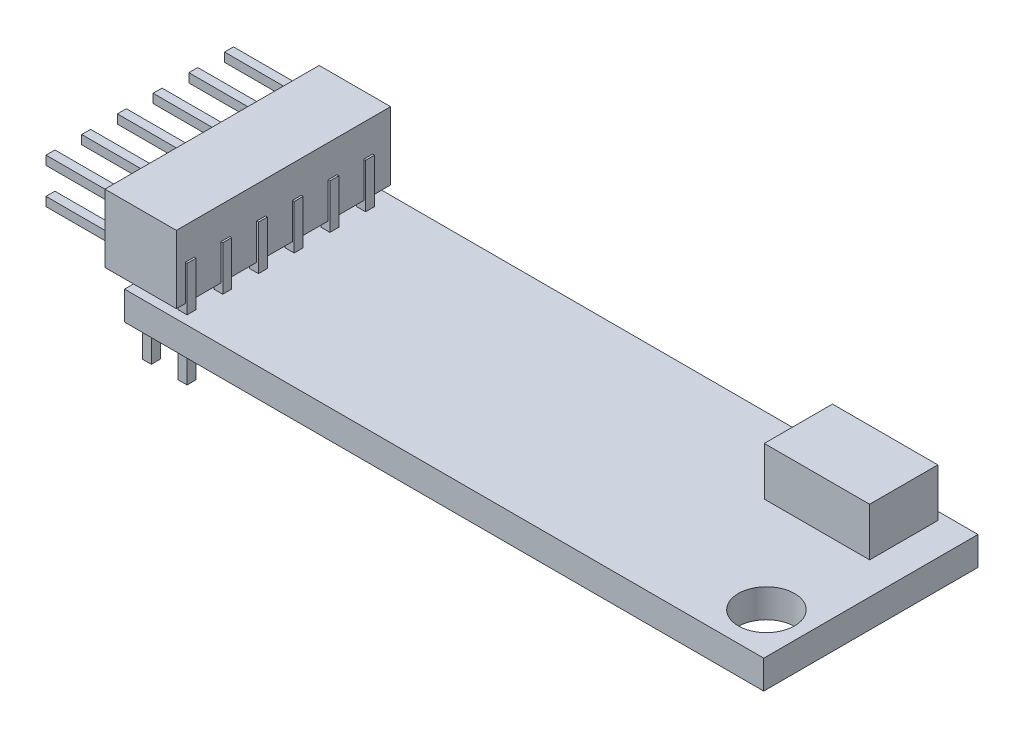
from build123d import *

# Parameters (mm, degrees)
SKETCH1_W                = 35.8
SKETCH1_H                = 12
BOARD_DEPTH              = 1.6
SKETCH2_R                = 1.575
HOLE_DEPTH               = 2.6
SKETCH3_W                = 5.9
SKETCH3_H                = 3.82
SETUP_SWITCH_DEPTH       = 2.7
SURFACE_START            = -3.4
SKETCH4_W                = 0.5
SKETCH4_H                = 0.5
SURFACE_CONNECTORS_DEPTH = 5.9
LPATTERN1_COUNT          = 6
LPATTERN1_PITCH          = 2
LPATTERN1_COUNT_DIR2     = 2
LPATTERN1_PITCH_DIR2     = 2
SKETCH5_W                = 4
SKETCH5_H                = 3.8
CONNECTOR_BODY_DEPTH     = 12
SKETCH6_W                = 0.5
SKETCH6_H                = 0.5
CONNECTOR_PIN_DEPTH      = 3.8
LPATTERN2_COUNT          = 6
LPATTERN2_PITCH          = 2
LPATTERN2_COUNT_DIR2     = 2
LPATTERN2_PITCH_DIR2     = 2


with BuildPart() as part:
    # Sketch1 → Board (new body)
    with BuildSketch(Plane(origin=(0, 0, 0), x_dir=(1, 0, 0), z_dir=(0, 1, 0))):
        Rectangle(SKETCH1_W, SKETCH1_H)
    extrude(amount=BOARD_DEPTH)

    # Sketch2 → Hole (cut, through all)
    with BuildSketch(Plane(origin=(0, 1.6, 0), x_dir=(-1, 0, 0), z_dir=(0, 1, 0))):
        with Locations(Location((-15.625, 3.575, 0), (0, 0, 90))):  # turned: the seam where the file's is
            Circle(SKETCH2_R)
    extrude(amount=-HOLE_DEPTH, mode=Mode.SUBTRACT)

    # Sketch3 → Setup Switch (add)
    with BuildSketch(Plane(origin=(0, 1.6, 0), x_dir=(-1, 0, 0), z_dir=(0, 1, 0))):
        with Locations((-13.15, -3.64)):
            Rectangle(SKETCH3_W, SKETCH3_H)
    extrude(amount=SETUP_SWITCH_DEPTH)

    # Sketch4 → Surface Connectors (add)
    with BuildSketch(Plane(origin=(0, 1.6, 0), x_dir=(-1, 0, 0), z_dir=(0, 1, 0)).offset(SURFACE_START)):
        with Locations((17.15, 5.25)):
            Rectangle(SKETCH4_W, SKETCH4_H)
    surface_connectors = extrude(amount=SURFACE_CONNECTORS_DEPTH)

    # LPattern1: Surface Connectors 6 × 2
    with Locations(*[(j * LPATTERN1_PITCH_DIR2, 0, -i * LPATTERN1_PITCH) for i in range(LPATTERN1_COUNT) for j in range(LPATTERN1_COUNT_DIR2) if (i, j) != (0, 0)]):
        add(surface_connectors)

    # Sketch5 → Connector Body (add)
    with BuildSketch(Plane.XY.offset(6)):
        with Locations((-17, 4)):
            Rectangle(SKETCH5_W, SKETCH5_H)
    extrude(amount=-CONNECTOR_BODY_DEPTH)

    # Sketch6 → Connector Pin (add)
    with BuildSketch(Plane.ZY.offset(19)):
        with Locations((5.25, 5.15)):
            Rectangle(SKETCH6_W, SKETCH6_H)
    connector_pin = extrude(amount=CONNECTOR_PIN_DEPTH)

    # LPattern2: Connector Pin 6 × 2
    with Locations(*[(0, -j * LPATTERN2_PITCH_DIR2, -i * LPATTERN2_PITCH) for i in range(LPATTERN2_COUNT) for j in range(LPATTERN2_COUNT_DIR2) if (i, j) != (0, 0)]):
        add(connector_pin)


solid = part.part
